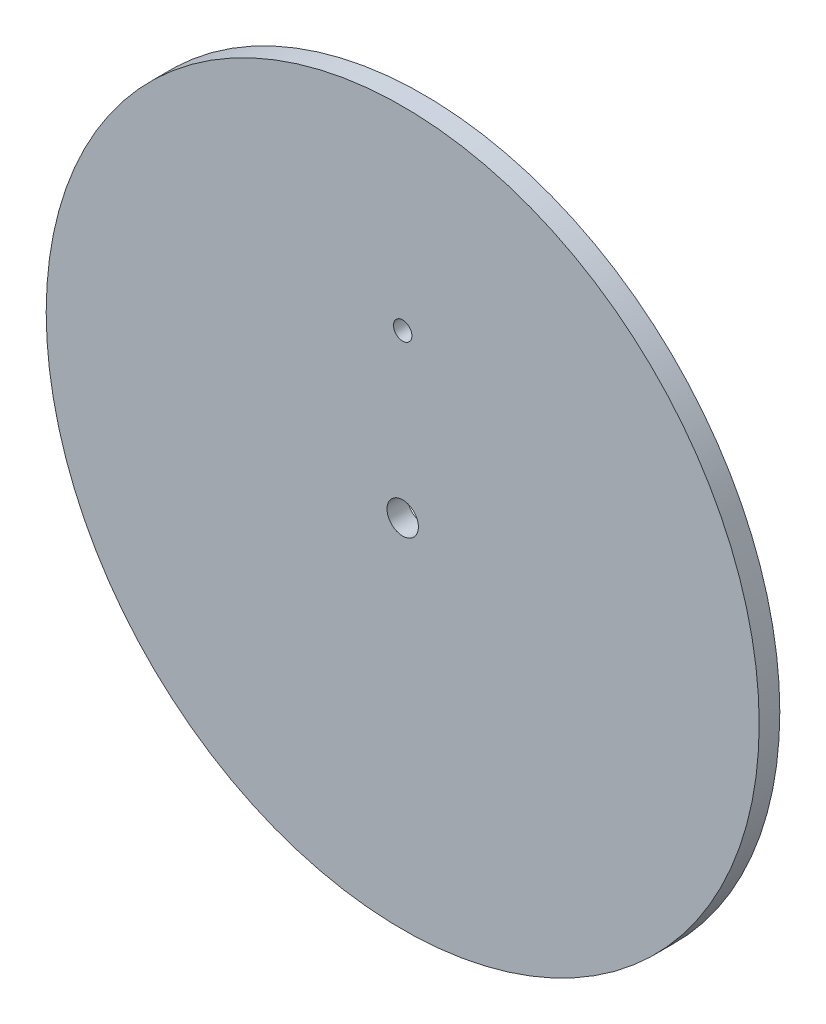
from build123d import *

# Parameters (mm, degrees)
SKETCH2_R           = 54.915
SKETCH2_R_2         = 2.415
SKETCH2_R_3         = 1.415
BOSS_EXTRUDE1_DEPTH = 3.175


with BuildPart() as part:
    # Sketch2 → Boss-Extrude1 (new body)
    with BuildSketch(Plane.XY):
        Circle(SKETCH2_R)
        Circle(SKETCH2_R_2, mode=Mode.SUBTRACT)
        with Locations((0, 25)):
            Circle(SKETCH2_R_3, mode=Mode.SUBTRACT)
    extrude(amount=BOSS_EXTRUDE1_DEPTH)


solid = part.part
